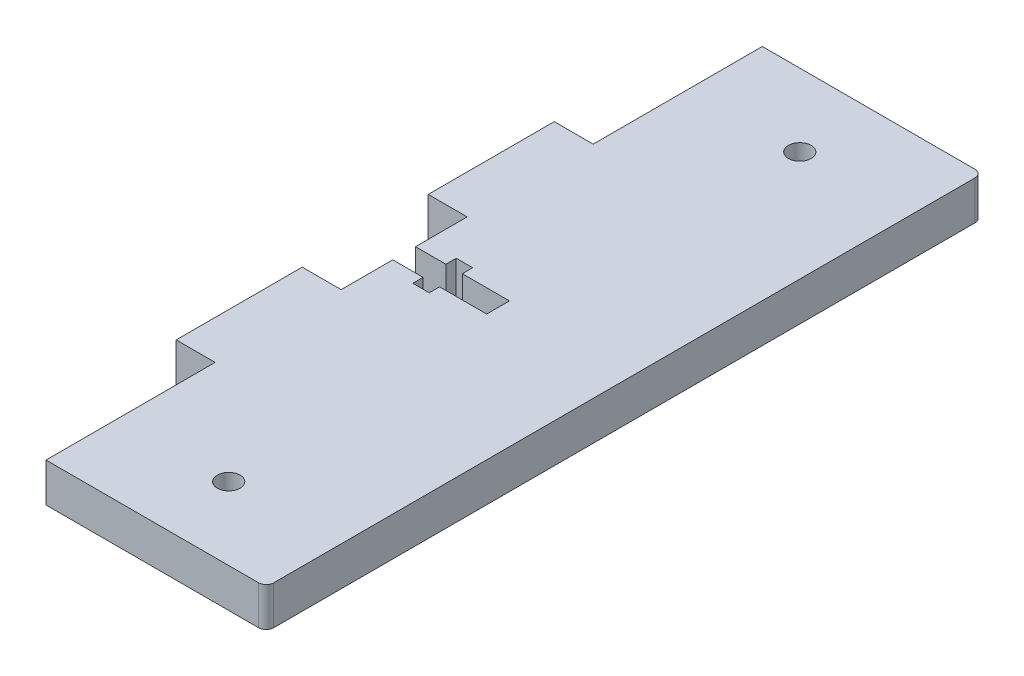
from build123d import *

# Parameters (mm, degrees)
SKETCH3_R           = 1.5
BOSS_EXTRUDE1_DEPTH = 5.13


with BuildPart() as part:
    # Sketch3 → Boss-Extrude1 (new body)
    with BuildSketch(Plane(origin=(0, 0, 0), x_dir=(1, 0, 0), z_dir=(0, 1, 0))):
        with BuildLine():
            Line((-15.990914087, -2.635364826), (-15.990914087, -9.436864826))
            Line((-15.990914087, -9.436864826), (-21.120914087, -9.436864826))
            Line((-21.120914087, -9.436864826), (-21.120914087, -26.036864826))
            Line((-21.120914087, -26.036864826), (-15.990914087, -26.036864826))
            Line((-15.990914087, -26.036864826), (-15.990914087, -48.316864826))
            Line((-15.990914087, -48.316864826), (12.009085913, -48.316864826))
            ThreePointArc((12.009085913, -48.316864826), (12.716192694, -48.023971608), (13.009085913, -47.316864826))
            Line((13.009085913, -47.316864826), (13.009085913, 45.043135174))
            ThreePointArc((13.009085913, 45.043135174), (12.716192694, 45.750241955), (12.009085913, 46.043135174))
            Line((12.009085913, 46.043135174), (-15.990914087, 46.043135174))
            Line((-15.990914087, 46.043135174), (-15.990914087, 23.763135174))
            Line((-15.990914087, 23.763135174), (-21.120914087, 23.763135174))
            Line((-21.120914087, 23.763135174), (-21.120914087, 7.163135174))
            Line((-21.120914087, 7.163135174), (-15.990914087, 7.163135174))
            Line((-15.990914087, 7.163135174), (-15.990914087, 0.361635174))
            Line((-15.990914087, 0.361635174), (-11.995914087, 0.361635174))
            Line((-11.995914087, 0.361635174), (-11.995914087, 1.720635174))
            Line((-11.995914087, 1.720635174), (-9.828914087, 1.720635174))
            Line((-9.828914087, 1.720635174), (-9.828914087, 0.361635174))
            Line((-9.828914087, 0.361635174), (-3.621914087, 0.361635174))
            Line((-3.621914087, 0.361635174), (-3.621914087, -2.635364826))
            Line((-3.621914087, -2.635364826), (-9.828914087, -2.635364826))
            Line((-9.828914087, -2.635364826), (-9.828914087, -3.994364826))
            Line((-9.828914087, -3.994364826), (-11.995914087, -3.994364826))
            Line((-11.995914087, -3.994364826), (-11.995914087, -2.635364826))
            Line((-11.995914087, -2.635364826), (-15.990914087, -2.635364826))
        make_face()
        with Locations((-1.490914087, -38.750864826)):
            Circle(SKETCH3_R, mode=Mode.SUBTRACT)
        with Locations((-1.490914087, 36.477135174)):
            Circle(SKETCH3_R, mode=Mode.SUBTRACT)
    extrude(amount=BOSS_EXTRUDE1_DEPTH)


solid = part.part
